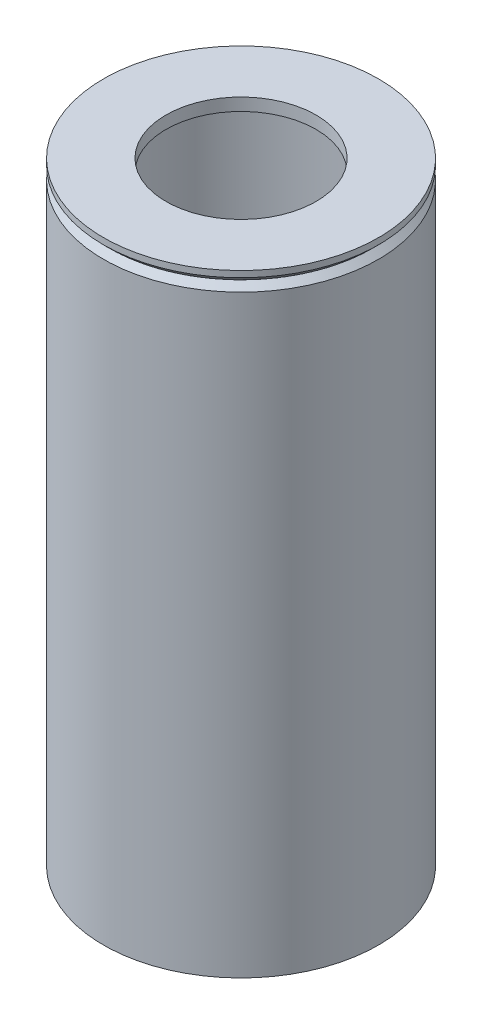
from build123d import *

# Parameters (mm, degrees)
SKETCH1_W     = 6.35
SKETCH1_H     = 304.8
SKETCH2_W     = 31.75
SKETCH2_H     = 6.35
CHAMFER1_SIZE = 3.175
CHAMFER2_SIZE = 3.175


with BuildPart() as part:
    # Sketch1 → Revolve1 (revolve)
    with BuildSketch(Plane.XY):
        with Locations((-66.675, -152.4)):
            Rectangle(SKETCH1_W, SKETCH1_H)
    revolve(axis=Axis((0, 0, 0), (0, 1, 0)))

    # Chamfer1
    chamfer1_edges = [part.edges().sort_by_distance(p)[0] for p in [
        (69.85, 0, 0),
    ]]
    chamfer(chamfer1_edges, length=CHAMFER1_SIZE)


with BuildPart() as body_2:
    # Sketch2 → Revolve2 (revolve)
    with BuildSketch(Plane.XY):
        with Locations((-53.975, 3.175)):
            Rectangle(SKETCH2_W, SKETCH2_H)
    revolve(axis=Axis((0, 0, 0), (0, 1, 0)))

    # Chamfer2
    chamfer2_edges = [body_2.edges().sort_by_distance(p)[0] for p in [
        (69.85, 0, 0),
    ]]
    chamfer(chamfer2_edges, length=CHAMFER2_SIZE)


solid = Compound([part.part, body_2.part])
